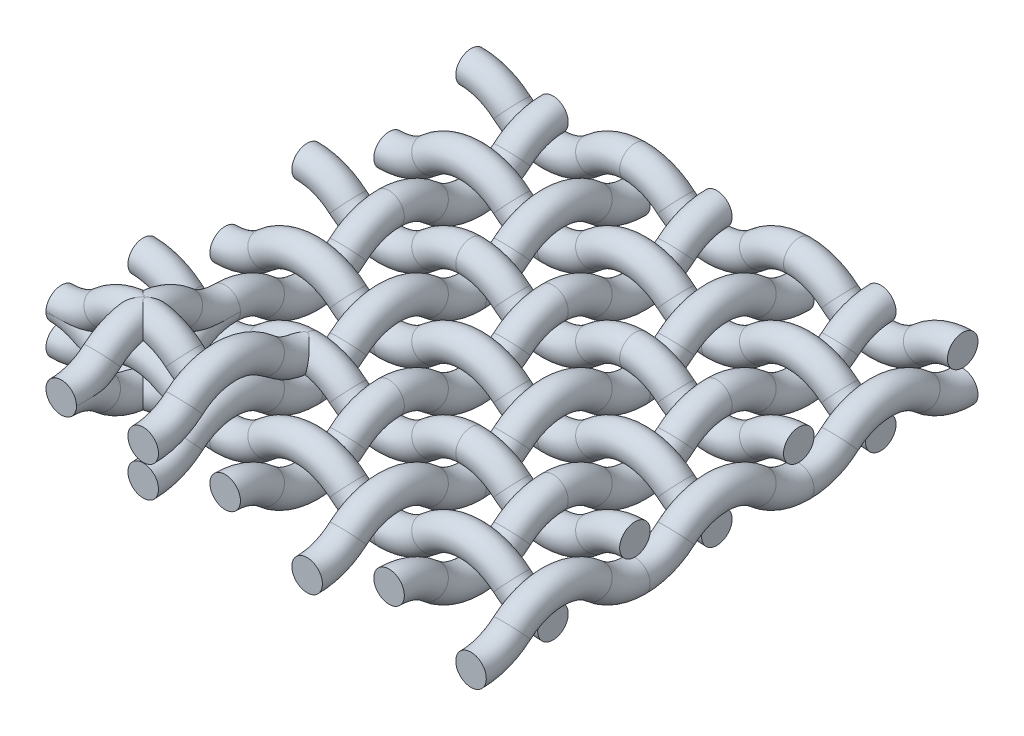
from build123d import *

# Parameters (mm, degrees)
SKIZZE2_R                = 3.72964473
LINEARES_MUSTER1_COUNT   = 2
LINEARES_MUSTER1_PITCH   = 20
LINEARES_MUSTER2_COUNT   = 2
LINEARES_MUSTER2_PITCH   = 7.55928946
LINEARES_MUSTER3_COUNT   = 2
LINEARES_MUSTER3_PITCH   = 20
LINEARES_MUSTER4_COUNT   = 3
LINEARES_MUSTER4_PITCH   = 40
LINEARES_MUSTER4_2_COUNT = 3
LINEARES_MUSTER4_2_PITCH = 40


with BuildPart() as part:
    # Austragung1: sweep along a path in Skizze1
    with BuildLine(Plane(origin=(20, 0, 0), x_dir=(0, 0, -1), z_dir=(1, 0, 0))) as austragung1_path:
        ThreePointArc((0, 0), (5.345224838, -0.976443297), (10, -3.77964473))
        ThreePointArc((10, -3.77964473), (14.654775162, -6.582846164), (20, -7.55928946))
    # Skizze2 → Austragung1 (sweep)
    with BuildSketch(Plane.XY):
        with Locations((20, 0)):
            Circle(SKIZZE2_R)
    sweep(path=austragung1_path.line)

    # Spiegeln1: part across plane


with BuildPart() as part_1:
    add(part.part)
    add(part.part.mirror(Plane(origin=(20, -7.55928946, -20), x_dir=(1, 0, 0), z_dir=(0, 0, 1))))


with BuildPart() as body_2:
    # Spiegeln2: mirrored copy
    add(part_1.part.mirror(Plane.ZX))


with BuildPart() as body_3:
    # Spiegeln3: mirrored copy
    add(body_2.part.mirror(Plane(origin=(0, 0, 0), x_dir=(-0.707106781, 0, 0.707106781), z_dir=(0.707106781, 0, 0.707106781))))


with BuildPart() as body_4:
    # Spiegeln3 2: mirrored copy
    add(part_1.part.mirror(Plane(origin=(0, 0, 0), x_dir=(-0.707106781, 0, 0.707106781), z_dir=(0.707106781, 0, 0.707106781))))


with BuildPart() as lineares_muster1_1:
    # Lineares Muster1: pattern copy
    add(body_2.part.moved(Location(Vector(1, 0, 0) * (1 * LINEARES_MUSTER1_PITCH))))


with BuildPart() as lineares_muster2_1:
    # Lineares Muster2: pattern copy
    add(lineares_muster1_1.part.moved(Location(Vector(0, -1, 0) * (1 * LINEARES_MUSTER2_PITCH))))


with BuildPart() as lineares_muster2_2:
    # Lineares Muster2: pattern copy
    add(body_3.part.moved(Location(Vector(0, -1, 0) * (1 * LINEARES_MUSTER2_PITCH))))


with BuildPart() as lineares_muster3_1:
    # Lineares Muster3: pattern copy
    add(body_4.part.moved(Location(Vector(0, 0, -1) * (1 * LINEARES_MUSTER3_PITCH))))


with BuildPart() as lineares_muster4_1:
    # Lineares Muster4: pattern copy
    add(part_1.part.moved(Location(Vector(0, 0, -1) * (1 * LINEARES_MUSTER4_PITCH))))


with BuildPart() as lineares_muster4_2:
    # Lineares Muster4: pattern copy
    add(part_1.part.moved(Location(Vector(0, 0, -1) * (2 * LINEARES_MUSTER4_PITCH))))


with BuildPart() as lineares_muster4_3:
    # Lineares Muster4: pattern copy
    add(lineares_muster2_2.part.moved(Location(Vector(0, 0, -1) * (1 * LINEARES_MUSTER4_PITCH))))


with BuildPart() as lineares_muster4_4:
    # Lineares Muster4: pattern copy
    add(lineares_muster2_2.part.moved(Location(Vector(0, 0, -1) * (2 * LINEARES_MUSTER4_PITCH))))


with BuildPart() as lineares_muster4_5:
    # Lineares Muster4: pattern copy
    add(lineares_muster3_1.part.moved(Location(Vector(0, 0, -1) * (1 * LINEARES_MUSTER4_PITCH))))


with BuildPart() as lineares_muster4_6:
    # Lineares Muster4: pattern copy
    add(lineares_muster3_1.part.moved(Location(Vector(0, 0, -1) * (2 * LINEARES_MUSTER4_PITCH))))


with BuildPart() as lineares_muster4_7:
    # Lineares Muster4: pattern copy
    add(lineares_muster2_1.part.moved(Location(Vector(0, 0, -1) * (1 * LINEARES_MUSTER4_PITCH))))


with BuildPart() as lineares_muster4_8:
    # Lineares Muster4: pattern copy
    add(lineares_muster2_1.part.moved(Location(Vector(0, 0, -1) * (2 * LINEARES_MUSTER4_PITCH))))


with BuildPart() as lineares_muster4_2_1:
    # Lineares Muster4 2: pattern copy
    add(part_1.part.moved(Location(Vector(1, 0, 0) * (1 * LINEARES_MUSTER4_2_PITCH))))


with BuildPart() as lineares_muster4_2_2:
    # Lineares Muster4 2: pattern copy
    add(part_1.part.moved(Location(Vector(1, 0, 0) * (2 * LINEARES_MUSTER4_2_PITCH))))


with BuildPart() as lineares_muster4_2_3:
    # Lineares Muster4 2: pattern copy
    add(lineares_muster2_2.part.moved(Location(Vector(1, 0, 0) * (1 * LINEARES_MUSTER4_2_PITCH))))


with BuildPart() as lineares_muster4_2_4:
    # Lineares Muster4 2: pattern copy
    add(lineares_muster2_2.part.moved(Location(Vector(1, 0, 0) * (2 * LINEARES_MUSTER4_2_PITCH))))


with BuildPart() as lineares_muster4_2_5:
    # Lineares Muster4 2: pattern copy
    add(lineares_muster3_1.part.moved(Location(Vector(1, 0, 0) * (1 * LINEARES_MUSTER4_2_PITCH))))


with BuildPart() as lineares_muster4_2_6:
    # Lineares Muster4 2: pattern copy
    add(lineares_muster3_1.part.moved(Location(Vector(1, 0, 0) * (2 * LINEARES_MUSTER4_2_PITCH))))


with BuildPart() as lineares_muster4_2_7:
    # Lineares Muster4 2: pattern copy
    add(lineares_muster2_1.part.moved(Location(Vector(1, 0, 0) * (1 * LINEARES_MUSTER4_2_PITCH))))


with BuildPart() as lineares_muster4_2_8:
    # Lineares Muster4 2: pattern copy
    add(lineares_muster2_1.part.moved(Location(Vector(1, 0, 0) * (2 * LINEARES_MUSTER4_2_PITCH))))


with BuildPart() as lineares_muster4_2_9:
    # Lineares Muster4 2: pattern copy
    add(lineares_muster4_1.part.moved(Location(Vector(1, 0, 0) * (1 * LINEARES_MUSTER4_2_PITCH))))


with BuildPart() as lineares_muster4_2_10:
    # Lineares Muster4 2: pattern copy
    add(lineares_muster4_1.part.moved(Location(Vector(1, 0, 0) * (2 * LINEARES_MUSTER4_2_PITCH))))


with BuildPart() as lineares_muster4_2_11:
    # Lineares Muster4 2: pattern copy
    add(lineares_muster4_2.part.moved(Location(Vector(1, 0, 0) * (1 * LINEARES_MUSTER4_2_PITCH))))


with BuildPart() as lineares_muster4_2_12:
    # Lineares Muster4 2: pattern copy
    add(lineares_muster4_2.part.moved(Location(Vector(1, 0, 0) * (2 * LINEARES_MUSTER4_2_PITCH))))


with BuildPart() as lineares_muster4_2_13:
    # Lineares Muster4 2: pattern copy
    add(lineares_muster4_3.part.moved(Location(Vector(1, 0, 0) * (1 * LINEARES_MUSTER4_2_PITCH))))


with BuildPart() as lineares_muster4_2_14:
    # Lineares Muster4 2: pattern copy
    add(lineares_muster4_3.part.moved(Location(Vector(1, 0, 0) * (2 * LINEARES_MUSTER4_2_PITCH))))


with BuildPart() as lineares_muster4_2_15:
    # Lineares Muster4 2: pattern copy
    add(lineares_muster4_4.part.moved(Location(Vector(1, 0, 0) * (1 * LINEARES_MUSTER4_2_PITCH))))


with BuildPart() as lineares_muster4_2_16:
    # Lineares Muster4 2: pattern copy
    add(lineares_muster4_4.part.moved(Location(Vector(1, 0, 0) * (2 * LINEARES_MUSTER4_2_PITCH))))


with BuildPart() as lineares_muster4_2_17:
    # Lineares Muster4 2: pattern copy
    add(lineares_muster4_5.part.moved(Location(Vector(1, 0, 0) * (1 * LINEARES_MUSTER4_2_PITCH))))


with BuildPart() as lineares_muster4_2_18:
    # Lineares Muster4 2: pattern copy
    add(lineares_muster4_5.part.moved(Location(Vector(1, 0, 0) * (2 * LINEARES_MUSTER4_2_PITCH))))


with BuildPart() as lineares_muster4_2_19:
    # Lineares Muster4 2: pattern copy
    add(lineares_muster4_6.part.moved(Location(Vector(1, 0, 0) * (1 * LINEARES_MUSTER4_2_PITCH))))


with BuildPart() as lineares_muster4_2_20:
    # Lineares Muster4 2: pattern copy
    add(lineares_muster4_6.part.moved(Location(Vector(1, 0, 0) * (2 * LINEARES_MUSTER4_2_PITCH))))


with BuildPart() as lineares_muster4_2_21:
    # Lineares Muster4 2: pattern copy
    add(lineares_muster4_7.part.moved(Location(Vector(1, 0, 0) * (1 * LINEARES_MUSTER4_2_PITCH))))


with BuildPart() as lineares_muster4_2_22:
    # Lineares Muster4 2: pattern copy
    add(lineares_muster4_7.part.moved(Location(Vector(1, 0, 0) * (2 * LINEARES_MUSTER4_2_PITCH))))


with BuildPart() as lineares_muster4_2_23:
    # Lineares Muster4 2: pattern copy
    add(lineares_muster4_8.part.moved(Location(Vector(1, 0, 0) * (1 * LINEARES_MUSTER4_2_PITCH))))


with BuildPart() as lineares_muster4_2_24:
    # Lineares Muster4 2: pattern copy
    add(lineares_muster4_8.part.moved(Location(Vector(1, 0, 0) * (2 * LINEARES_MUSTER4_2_PITCH))))


solid = Compound([part_1.part, body_2.part, body_3.part, body_4.part, lineares_muster1_1.part, lineares_muster2_1.part, lineares_muster2_2.part, lineares_muster3_1.part, lineares_muster4_1.part, lineares_muster4_2.part, lineares_muster4_3.part, lineares_muster4_4.part, lineares_muster4_5.part, lineares_muster4_6.part, lineares_muster4_7.part, lineares_muster4_8.part, lineares_muster4_2_1.part, lineares_muster4_2_2.part, lineares_muster4_2_3.part, lineares_muster4_2_4.part, lineares_muster4_2_5.part, lineares_muster4_2_6.part, lineares_muster4_2_7.part, lineares_muster4_2_8.part, lineares_muster4_2_9.part, lineares_muster4_2_10.part, lineares_muster4_2_11.part, lineares_muster4_2_12.part, lineares_muster4_2_13.part, lineares_muster4_2_14.part, lineares_muster4_2_15.part, lineares_muster4_2_16.part, lineares_muster4_2_17.part, lineares_muster4_2_18.part, lineares_muster4_2_19.part, lineares_muster4_2_20.part, lineares_muster4_2_21.part, lineares_muster4_2_22.part, lineares_muster4_2_23.part, lineares_muster4_2_24.part])
